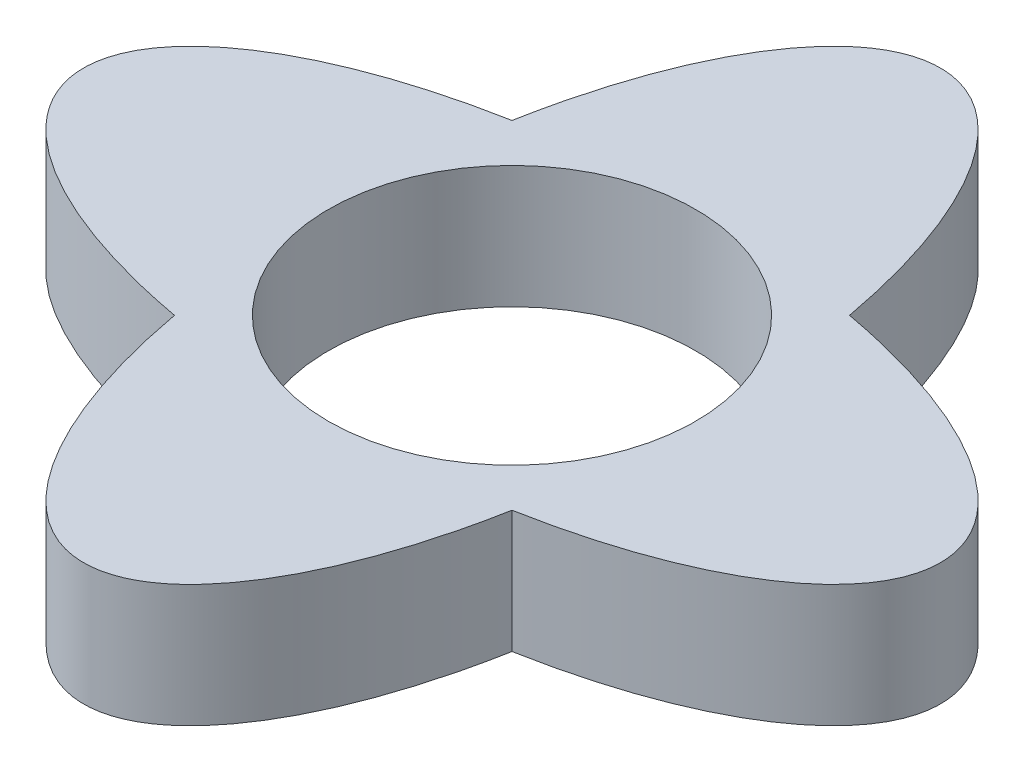
from build123d import *

# Parameters (mm, degrees)
SKETCH1_R           = 3
BOSS_EXTRUDE1_DEPTH = 2


with BuildPart() as part:
    # Sketch1 → Boss-Extrude1 (new body)
    with BuildSketch(Plane(origin=(0, 0, 0), x_dir=(1, 0, 0), z_dir=(0, 1, 0))):
        with BuildLine():
            add(Edge.make_bspline(
                [(-2.75743509, -2.75743509), (0, -17.770137247), (2.75743509, -2.75743509)],
                knots=[1.975688113, 1.975688113, 1.975688113, 4.307497194, 4.307497194, 4.307497194], degree=2, weights=[1, 0.393919299, 1]))
            add(Edge.make_bspline(
                [(2.75743509, -2.75743509), (17.770137247, 0), (2.75743509, 2.75743509)],
                knots=[5.117280767, 5.117280767, 5.117280767, 7.449089848, 7.449089848, 7.449089848], degree=2, weights=[1, 0.393919299, 1]))
            add(Edge.make_bspline(
                [(2.75743509, 2.75743509), (0, 17.770137247), (-2.75743509, 2.75743509)],
                knots=[5.117280767, 5.117280767, 5.117280767, 7.449089848, 7.449089848, 7.449089848], degree=2, weights=[1, 0.393919299, 1]))
            add(Edge.make_bspline(
                [(-2.75743509, 2.75743509), (-17.770137247, 0), (-2.75743509, -2.75743509)],
                knots=[1.975688113, 1.975688113, 1.975688113, 4.307497194, 4.307497194, 4.307497194], degree=2, weights=[1, 0.393919299, 1]))
        make_face()
        Circle(SKETCH1_R, mode=Mode.SUBTRACT)
    extrude(amount=BOSS_EXTRUDE1_DEPTH)


solid = part.part
